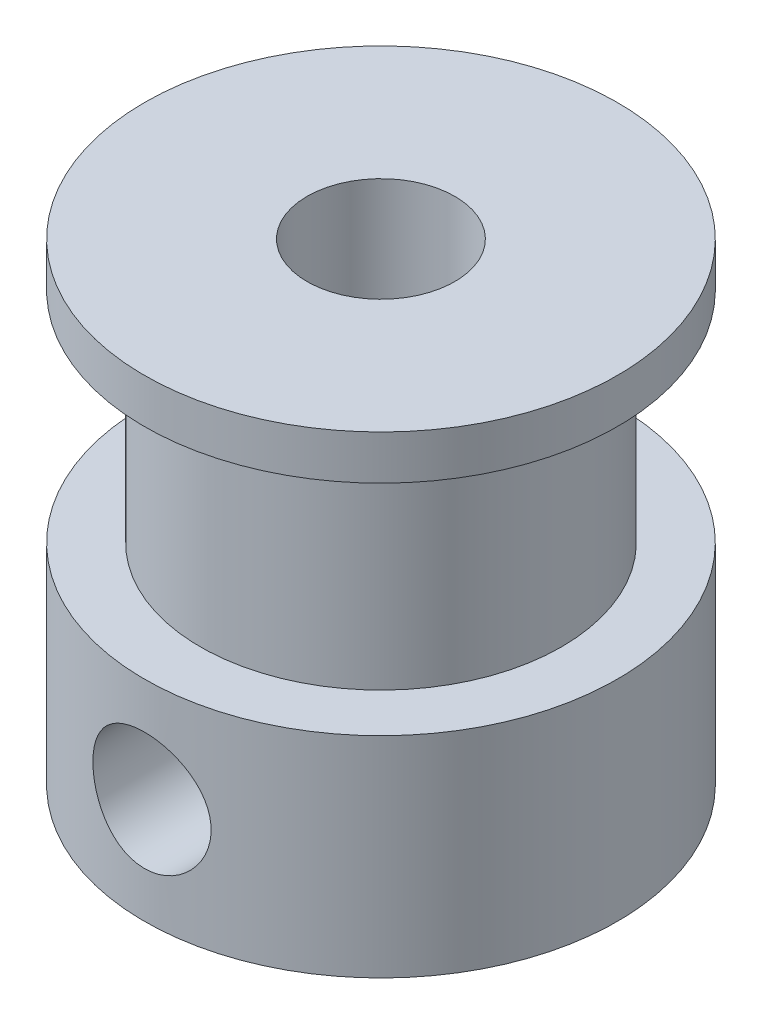
from build123d import *

# Parameters (mm, degrees)
SKETCH2_R          = 2
CUT_EXTRUDE1_DEPTH = 10


with BuildPart() as part:
    # Sketch1 → Revolve1 (revolve)
    with BuildSketch(Plane.XY):
        Polygon((0, 0), (0, 16), (-5.5, 16), (-5.5, 14.5), (-3.61, 14.5), (-3.61, 7.1), (-5.5, 7.1), (-5.5, 0), align=None)
    revolve(axis=Axis((2.5, 19.494779208, 0), (0, -1, 0)))

    # Sketch2 → Cut-Extrude1 (cut)
    with BuildSketch(Plane.XY):
        with Locations((2.5, 3.55)):
            Circle(SKETCH2_R)
    extrude(amount=CUT_EXTRUDE1_DEPTH, mode=Mode.SUBTRACT)


solid = part.part
